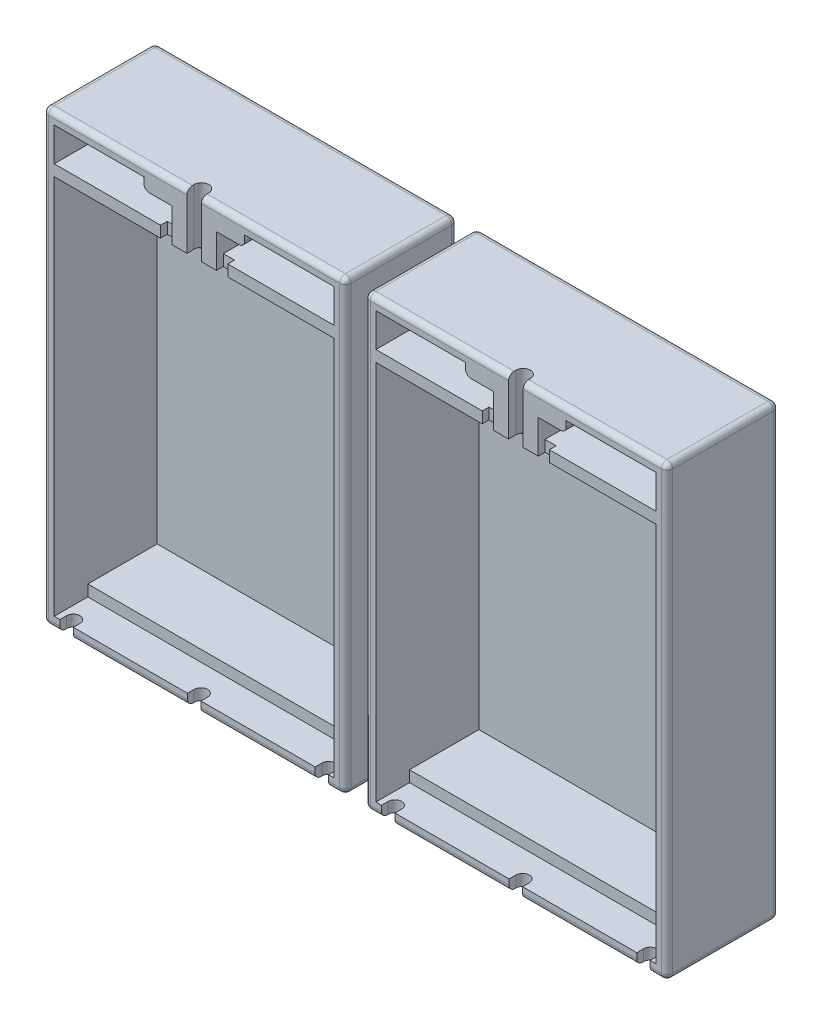
from build123d import *

# Parameters (mm, degrees)
SKETCH_1_W           = 27
SKETCH_1_H           = 40
EXTRUDE_1_DEPTH      = 10
SKETCH_2_W           = 25
SKETCH_2_H           = 31
CUT_EXTRUDE_1_DEPTH  = 9.2
CUT_EXTRUDE_2_DEPTH  = 9
SKETCH_8_W           = 25
SKETCH_8_H           = 2
SKETCH_8_H_2         = 1
CUT_EXTRUDE_7_DEPTH  = 3
SKETCH_9_W           = 8
SKETCH_9_H           = 2
CUT_EXTRUDE_8_DEPTH  = 6.2
CUT_EXTRUDE_9_DEPTH  = 0.65
SKETCH_10_3_W        = 1.2
SKETCH_10_3_H        = 1
CUT_EXTRUDE_10_DEPTH = 0.6
SKETCH_11_R          = 0.65
CUT_EXTRUDE_11_DEPTH = 6
SKETCH_12_R          = 0.6
CUT_EXTRUDE_12_DEPTH = 2
SKETCH_13_W          = 1
SKETCH_13_H          = 1
CUT_EXTRUDE_13_DEPTH = 0.6
FILLET_1_R           = 0.5
FILLET_2_R           = 0.5
FILLET_4_R           = 0.5
FILLET_5_R           = 0.5


with BuildPart() as part:
    # Sketch 1 → Extrude 1 (new body)
    with BuildSketch(Plane.XY):
        with Locations((13.5, 20)):
            Rectangle(SKETCH_1_W, SKETCH_1_H)
    extrude(amount=EXTRUDE_1_DEPTH)

    # Sketch 2 → Cut-Extrude 1 (cut)
    with BuildSketch(Plane.XY.offset(10)):
        with Locations((13.5, 17.5)):
            Rectangle(SKETCH_2_W, SKETCH_2_H)
    extrude(amount=-CUT_EXTRUDE_1_DEPTH, mode=Mode.SUBTRACT)

    # Sketch 3 → Cut-Extrude 2 (cut)
    with BuildSketch(Plane.XY.offset(10)):
        Polygon((1, 39), (9, 39), (9, 38), (11.5, 38), (11.5, 36), (9, 36), (1, 36), align=None)
        Polygon((15.5, 36), (15.5, 38), (18, 38), (18, 39), (26, 39), (26, 36), (18, 36), align=None)
    extrude(amount=-CUT_EXTRUDE_2_DEPTH, mode=Mode.SUBTRACT)

    # Sketch 8 → Cut-Extrude 7 (cut)
    with BuildSketch(Plane.XY.offset(10)):
        with Locations((13.5, 34)):
            Rectangle(SKETCH_8_W, SKETCH_8_H)
        with Locations((13.5, 1.5)):
            Rectangle(SKETCH_8_W, SKETCH_8_H_2)
    extrude(amount=-CUT_EXTRUDE_7_DEPTH, mode=Mode.SUBTRACT)

    # Sketch 9 → Cut-Extrude 8 (cut)
    with BuildSketch(Plane.XY.offset(7)):
        with Locations((5, 34)):
            Rectangle(SKETCH_9_W, SKETCH_9_H)
        with Locations((22, 34)):
            Rectangle(SKETCH_9_W, SKETCH_9_H)
    extrude(amount=-CUT_EXTRUDE_8_DEPTH, mode=Mode.SUBTRACT)

    # Sketch 10 → Cut-Extrude 9 (cut)
    with BuildSketch(Plane.XY.offset(10)):
        Polygon((14.15, 40), (13.5, 40), (12.85, 40), (12.85, 35), (13.5, 35), (14.15, 35), align=None)
    extrude(amount=-CUT_EXTRUDE_9_DEPTH, mode=Mode.SUBTRACT)

    # Sketch 10_3 → Cut-Extrude 10 (cut)
    with BuildSketch(Plane.XY.offset(10)):
        Polygon((12.9, 0), (13.5, 0), (14.1, 0), (14.1, 1), (13.5, 1), (12.9, 1), align=None)
        with Locations((2.1, 0.5)):
            Rectangle(SKETCH_10_3_W, SKETCH_10_3_H)
        with Locations((24.9, 0.5)):
            Rectangle(SKETCH_10_3_W, SKETCH_10_3_H)
    extrude(amount=-CUT_EXTRUDE_10_DEPTH, mode=Mode.SUBTRACT)

    # Sketch 11 → Cut-Extrude 11 (cut, through all)
    with BuildSketch(Plane.XZ.offset(-35)):
        with Locations((13.5, 9.35)):
            Circle(SKETCH_11_R)
    extrude(amount=-CUT_EXTRUDE_11_DEPTH, mode=Mode.SUBTRACT)

    # Sketch 12 → Cut-Extrude 12 (cut, through all)
    with BuildSketch(Plane(origin=(0, 1, 0), x_dir=(1, 0, 0), z_dir=(0, 1, 0))):
        with Locations((13.5, -9.4)):
            Circle(SKETCH_12_R)
        with Locations((24.9, -9.4)):
            Circle(SKETCH_12_R)
        with Locations((2.1, -9.4)):
            Circle(SKETCH_12_R)
    extrude(amount=-CUT_EXTRUDE_12_DEPTH, mode=Mode.SUBTRACT)

    # Sketch 13 → Cut-Extrude 13 (cut)
    with BuildSketch(Plane.XY.offset(10)):
        with Locations((11, 35.5)):
            Rectangle(SKETCH_13_W, SKETCH_13_H)
        with Locations((16, 35.5)):
            Rectangle(SKETCH_13_W, SKETCH_13_H)
    extrude(amount=-CUT_EXTRUDE_13_DEPTH, mode=Mode.SUBTRACT)

    # Fillet 1
    fillet_1_edges = [part.edges().sort_by_distance(p)[0] for p in [
        (18, 33, 3.9),
        (9, 33, 3.9),
    ]]
    fillet(fillet_1_edges, radius=FILLET_1_R)

    # Fillet 2
    fillet_2_edges = [part.edges().sort_by_distance(p)[0] for p in [
        (13.5, 40, 0),
        (27, 20, 0),
        (13.5, 0, 0),
        (0, 20, 0),
        (0, 40, 5),
        (27, 40, 5),
        (27, 0, 5),
        (0, 0, 5),
    ]]
    fillet(fillet_2_edges, radius=FILLET_2_R)

    # Fillet 4
    fillet_4_edges = [part.edges().sort_by_distance(p)[0] for p in [
        (9, 38, 5.5),
        (18, 38, 5.5),
    ]]
    fillet(fillet_4_edges, radius=FILLET_4_R)

    # Fillet 5
    fillet_5_edges = [part.edges().sort_by_distance(p)[0] for p in [
        (6.675, 40, 10),
        (19.2, 0, 10),
        (26, 0, 10),
        (7.8, 0, 10),
        (0, 20, 10),
        (20.325, 40, 10),
        (1, 0, 10),
        (0.146446609, 0.146446609, 10),
        (0.146446609, 39.853553391, 10),
        (27, 20, 10),
        (26.853553391, 0.146446609, 10),
        (26.853553391, 39.853553391, 10),
    ]]
    fillet(fillet_5_edges, radius=FILLET_5_R)


with BuildPart() as body_2:
    # Move Body 1: copy of part
    add(part.part.moved(Location((28.728815085, 0, 0))))


solid = Compound([part.part, body_2.part])
